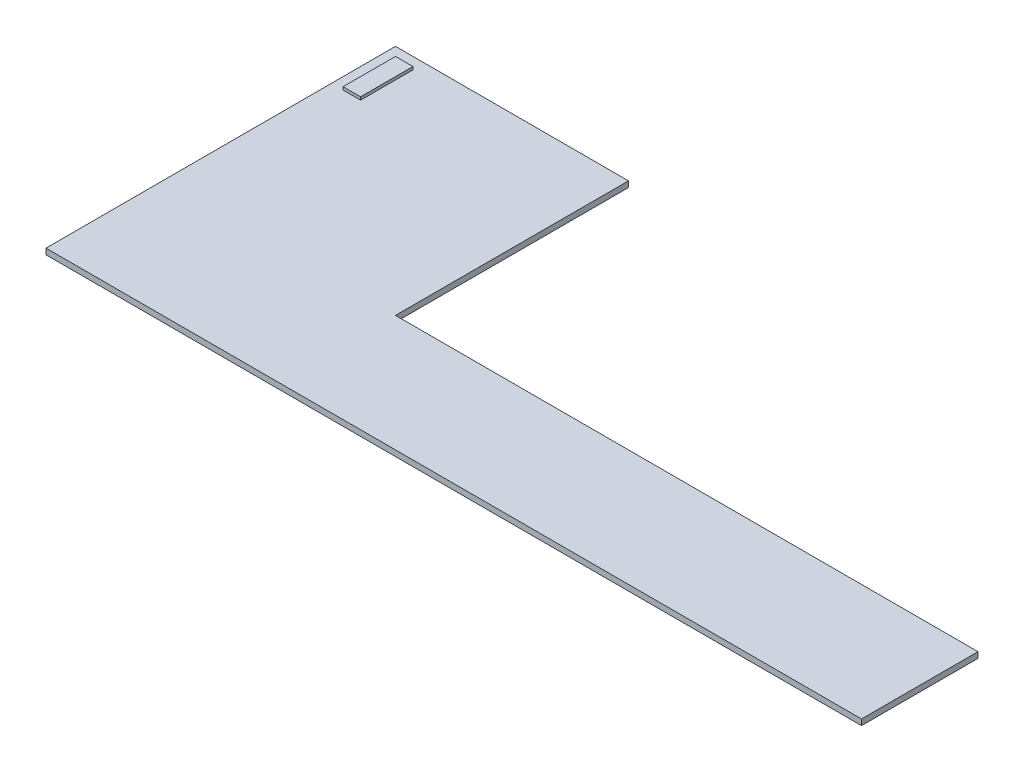
from build123d import *

# Parameters (mm, degrees)
BOSS_EXTRUDE1_DEPTH = 2.54
SKETCH2_W           = 7.62
SKETCH2_H           = 7.62
BOSS_EXTRUDE2_DEPTH = 1.27


with BuildPart() as part:
    # Sketch1 → Boss-Extrude1 (new body)
    with BuildSketch(Plane(origin=(0, 0, 0), x_dir=(1, 0, 0), z_dir=(0, 1, 0))):
        Polygon((0, 0), (0, 101.6), (-101.6, 101.6), (-101.6, -50.8), (254, -50.8), (254, 0), align=None)
    extrude(amount=BOSS_EXTRUDE1_DEPTH)

    # Sketch2 → Boss-Extrude2 (add)
    with BuildSketch(Plane(origin=(0, 2.54, 0), x_dir=(1, 0, 0), z_dir=(0, 1, 0))):
        with Locations((-92.71, 92.71)):
            Rectangle(SKETCH2_W, SKETCH2_H)
        with Locations((-92.71, 85.09)):
            Rectangle(SKETCH2_W, SKETCH2_H)
        with Locations((-92.71, 77.47)):
            Rectangle(SKETCH2_W, SKETCH2_H)
    extrude(amount=BOSS_EXTRUDE2_DEPTH)


solid = part.part
